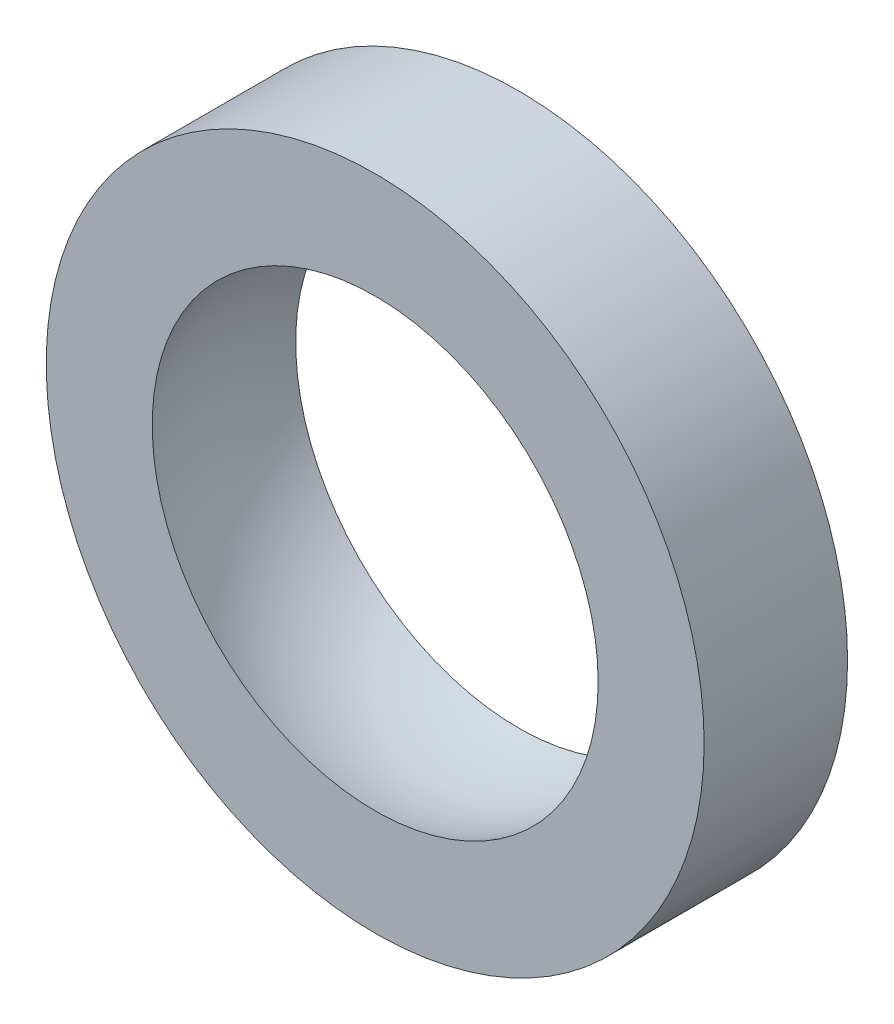
from build123d import *


with BuildPart() as part:
    # Sketch1 → Revolve1 (revolve)
    with BuildSketch(Plane(origin=(0, 0, 0), x_dir=(0, 0, -1), z_dir=(1, 0, 0))):
        with BuildLine():
            Line((-1.45833938, -4.533723911), (-1.45833938, -6.688630503))
            Line((-1.45833938, -6.688630503), (1.45833938, -6.688630503))
            Line((1.45833938, -6.688630503), (1.45833938, -4.533723911))
            ThreePointArc((1.45833938, -4.533723911), (0, -4.7625), (-1.45833938, -4.533723911))
        make_face()
    revolve(axis=Axis((0, 0, 15.314276063), (0, 0, -1)))


solid = part.part
